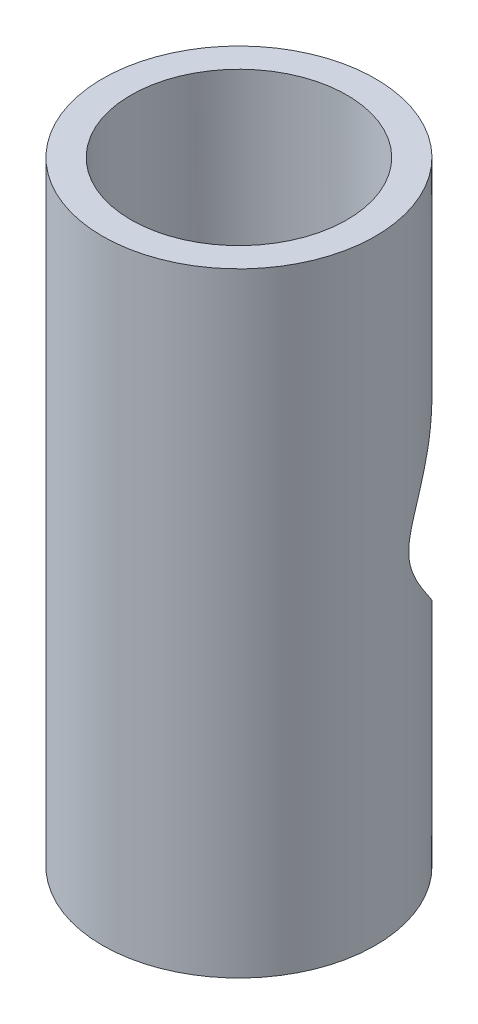
from build123d import *

# Parameters (mm, degrees)
SKETCH1_R           = 15.24
BOSS_EXTRUDE1_DEPTH = 68.58
SKETCH2_R           = 14.605
CUT_EXTRUDE1_DEPTH  = 68.58
SKETCH3_R           = 12.065
CUT_EXTRUDE2_DEPTH  = 68.58


with BuildPart() as part:
    # Sketch1 → Boss-Extrude1 (new body)
    with BuildSketch(Plane(origin=(0, 0, 0), x_dir=(1, 0, 0), z_dir=(0, 1, 0))):
        Circle(SKETCH1_R)
    extrude(amount=BOSS_EXTRUDE1_DEPTH)

    # Sketch2 → Cut-Extrude1 (cut)
    with BuildSketch(Plane.XY):
        with Locations((0, 35.56)):
            Circle(SKETCH2_R)
    extrude(amount=-CUT_EXTRUDE1_DEPTH, mode=Mode.SUBTRACT)

    # Sketch3 → Cut-Extrude2 (cut)
    with BuildSketch(Plane(origin=(0, 68.58, 0), x_dir=(-1, 0, 0), z_dir=(0, 1, 0))):
        Circle(SKETCH3_R)
    extrude(amount=-CUT_EXTRUDE2_DEPTH, mode=Mode.SUBTRACT)


solid = part.part
